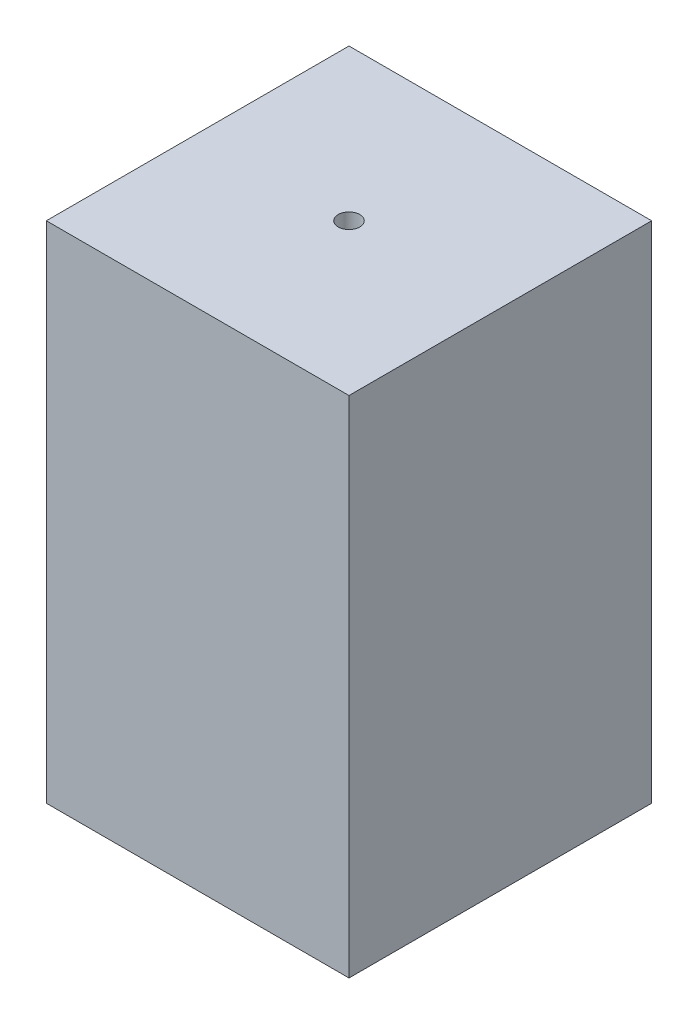
from build123d import *

# Parameters (mm, degrees)
SKETCH1_W           = 120
SKETCH1_H           = 120
SKETCH1_R           = 4.285714286
BOSS_EXTRUDE1_DEPTH = 10
SKETCH2_W           = 120
SKETCH2_H           = 120
SKETCH2_W_2         = 100
SKETCH2_H_2         = 100
BOSS_EXTRUDE2_DEPTH = 190
SKETCH3_R           = 3.25
CUT_EXTRUDE1_DEPTH  = 15
CUT_EXTRUDE2_REACH  = 122
SKETCH4_R           = 6.5


with BuildPart() as part:
    # Sketch1 → Boss-Extrude1 (new body)
    with BuildSketch(Plane(origin=(0, 0, 0), x_dir=(1, 0, 0), z_dir=(0, 1, 0))):
        Rectangle(SKETCH1_W, SKETCH1_H)
        Circle(SKETCH1_R, mode=Mode.SUBTRACT)
    extrude(amount=BOSS_EXTRUDE1_DEPTH)

    # Sketch2 → Boss-Extrude2 (add)
    with BuildSketch(Plane.XZ):
        Rectangle(SKETCH2_W, SKETCH2_H)
        Rectangle(SKETCH2_W_2, SKETCH2_H_2, mode=Mode.SUBTRACT)
    extrude(amount=BOSS_EXTRUDE2_DEPTH)

    # Sketch3 → Cut-Extrude1 (cut)
    with BuildSketch(Plane.XZ.offset(190)):
        with Locations((-55, -55)):
            Circle(SKETCH3_R)
        with Locations((55, 55)):
            Circle(SKETCH3_R)
        with Locations((-55, 55)):
            Circle(SKETCH3_R)
        with Locations((55, -55)):
            Circle(SKETCH3_R)
    extrude(amount=-CUT_EXTRUDE1_DEPTH, mode=Mode.SUBTRACT)

    # Sketch4 → Cut-Extrude2 (cut, up to next)
    with BuildSketch(Plane(origin=(0, 0, -60), x_dir=(-1, 0, 0), z_dir=(0, 0, -1)), mode=Mode.PRIVATE) as cut_extrude2_sk1:
        with Locations((0, -174.75)):
            Circle(SKETCH4_R)
    cut_extrude2_tool1 = extrude(cut_extrude2_sk1.sketch, amount=-CUT_EXTRUDE2_REACH, mode=Mode.PRIVATE) & part.part
    add(cut_extrude2_tool1.solids().sort_by_distance((0, -174.75, -60))[0], mode=Mode.SUBTRACT)


solid = part.part
